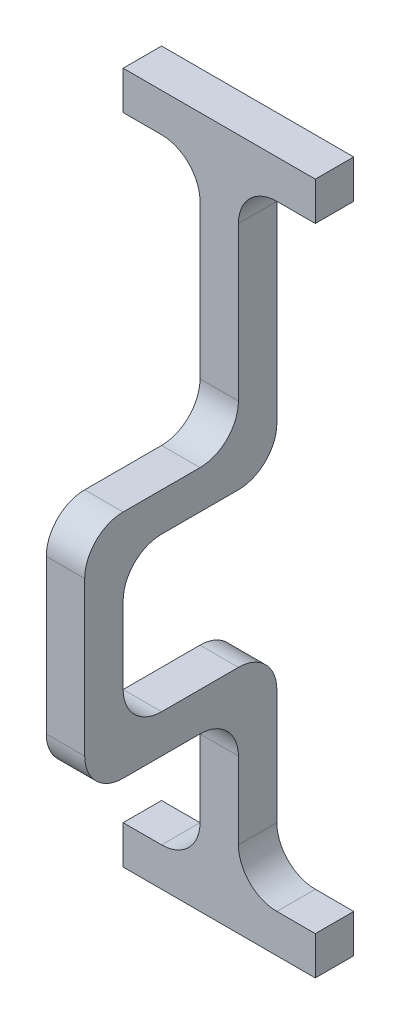
from build123d import *

# Parameters (mm, degrees)
BOSS_EXTRUDE1_DEPTH = 10
SKETCH2_W           = 10
SKETCH2_H           = 10
BOSS_EXTRUDE2_DEPTH = 20
FILLET1_R           = 10


with BuildPart() as part:
    # Sketch1 → Boss-Extrude1 (new body)
    with BuildSketch(Plane(origin=(0, 0, 0), x_dir=(0, 0, -1), z_dir=(1, 0, 0))):
        Polygon((0, 0), (0, 80), (-10, 80), (-10, 10), (-50, 10), (-50, -50), (-10, -50), (-10, -100), (0, -100), (0, -40), (-40, -40), (-40, 0), align=None)
    extrude(amount=BOSS_EXTRUDE1_DEPTH)

    # Sketch2 → Boss-Extrude2 (add)
    with BuildSketch(Plane(origin=(10, 0, 0), x_dir=(0, 0, -1), z_dir=(1, 0, 0))):
        with Locations((-5, 75)):
            Rectangle(SKETCH2_W, SKETCH2_H)
        with Locations((-5, -95)):
            Rectangle(SKETCH2_W, SKETCH2_H)
    boss_extrude2 = extrude(amount=BOSS_EXTRUDE2_DEPTH)

    # Mirror1: Boss-Extrude2 across plane
    add(boss_extrude2.mirror(Plane.ZY.offset(-5)))

    # Fillet1
    fillet1_edges = [part.edges().sort_by_distance(p)[0] for p in [
        (10, -90, 5),
        (5, -40, 40),
        (0, -90, 5),
        (0, 70, 5),
        (5, -40, 0),
        (5, 0, 0),
        (10, 70, 5),
        (5, -50, 50),
        (5, 0, 40),
        (5, 10, 50),
        (5, -50, 10),
        (5, 10, 10),
    ]]
    fillet(fillet1_edges, radius=FILLET1_R)


solid = part.part
